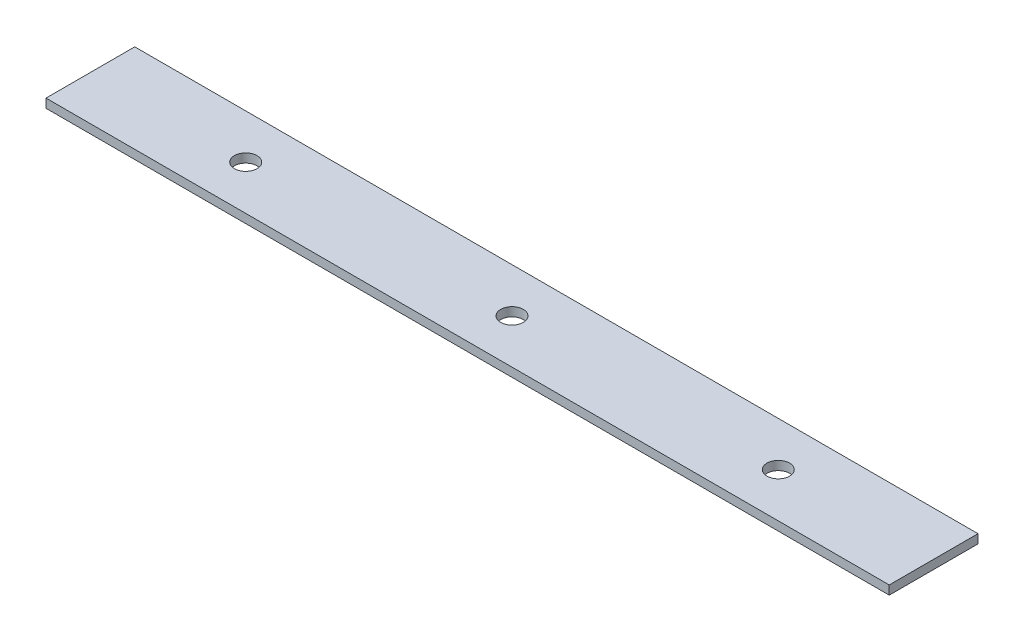
from build123d import *

# Parameters (mm, degrees)
SKETCH1_W           = 241.3
SKETCH1_H           = 25.4
SKETCH1_R           = 3.2385
BOSS_EXTRUDE1_DEPTH = 2.54


with BuildPart() as part:
    # Sketch1 → Boss-Extrude1 (new body)
    with BuildSketch(Plane(origin=(0, 0, 0), x_dir=(1, 0, 0), z_dir=(0, 1, 0))):
        with Locations((120.65, 12.7)):
            Rectangle(SKETCH1_W, SKETCH1_H)
        with Locations((196.85, 12.7)):
            Circle(SKETCH1_R, mode=Mode.SUBTRACT)
        with Locations((120.65, 12.7)):
            Circle(SKETCH1_R, mode=Mode.SUBTRACT)
        with Locations((44.45, 12.7)):
            Circle(SKETCH1_R, mode=Mode.SUBTRACT)
    extrude(amount=BOSS_EXTRUDE1_DEPTH)


solid = part.part
